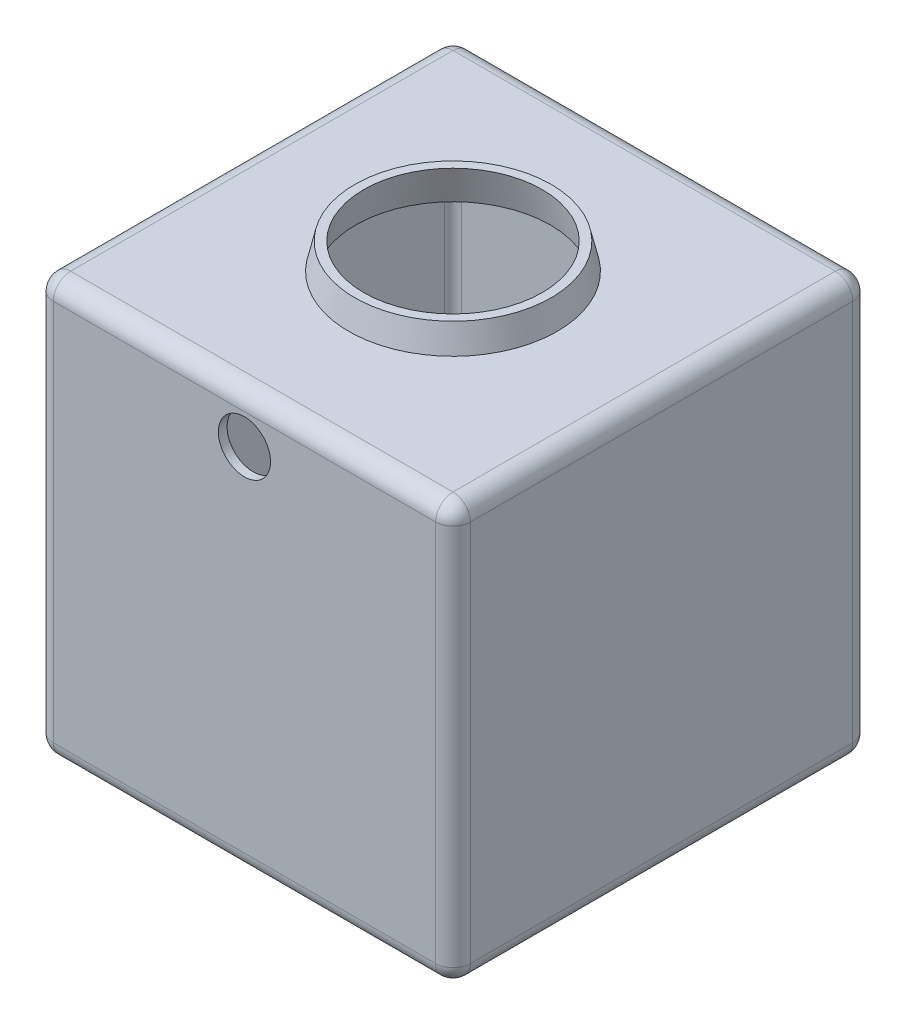
from build123d import *

# Parameters (mm, degrees)
SKETCH1_W               = 480
SKETCH1_H               = 480
BOSS_EXTRUDE1_DEPTH     = 240
FILLET1_R               = 20
SHELL1_T                = -10
SKETCH3_R               = 30
CUT_EXTRUDE1_DEPTH      = 741.337760755
CUT_EXTRUDE1_DEPTH_BACK = 741.337760755
SCALE1_SCALE            = 0.5


with BuildPart() as part:
    # Sketch1 → Boss-Extrude1 (new, symmetric)
    with BuildSketch(Plane.XY):
        with Locations((240, -240)):
            Rectangle(SKETCH1_W, SKETCH1_H)
    extrude(amount=BOSS_EXTRUDE1_DEPTH, both=True)

    # Fillet1
    fillet1_edges = [part.edges().sort_by_distance(p)[0] for p in [
        (480, -240, 240),
        (240, 0, 240),
        (0, -240, 240),
        (240, 0, -240),
        (480, -240, -240),
        (240, -480, -240),
        (0, -240, -240),
        (0, 0, 0),
        (480, 0, 0),
        (480, -480, 0),
        (0, -480, 0),
        (240, -480, 240),
    ]]
    fillet(fillet1_edges, radius=FILLET1_R)

    # Sketch2 → Revolve1 (revolve)
    with BuildSketch(Plane.XY, mode=Mode.PRIVATE) as revolve1_sk:
        Polygon((240, 0), (360, 0), (353, 30), (240, 30), align=None)
        Polygon((360, -480), (353, -510), (240, -510), (240, -480), align=None)
    revolve(revolve1_sk.sketch.rotate(Axis((240, 0, 0), (0, 1, 0)), 90), axis=Axis((240, 0, 0), (0, 1, 0)))

    # Shell1
    shell1_openings = [part.faces().sort_by_distance(p)[0] for p in [
        (240, 30, 0),
        (240, -510, 0),
    ]]
    offset(amount=SHELL1_T, openings=shell1_openings, kind=Kind.INTERSECTION)

    # Sketch3 → Cut-Extrude1 (cut, two sides)
    with BuildSketch(Plane.XY) as cut_extrude1_sk:
        with Locations((240, -55)):
            Circle(SKETCH3_R)
    extrude(amount=CUT_EXTRUDE1_DEPTH, mode=Mode.SUBTRACT)
    extrude(cut_extrude1_sk.sketch, amount=-CUT_EXTRUDE1_DEPTH_BACK, mode=Mode.SUBTRACT)


with BuildPart() as part_1:
    # Scale1: scaled about (0, 0, 0)
    add(part.part.scale(SCALE1_SCALE))


solid = part_1.part
